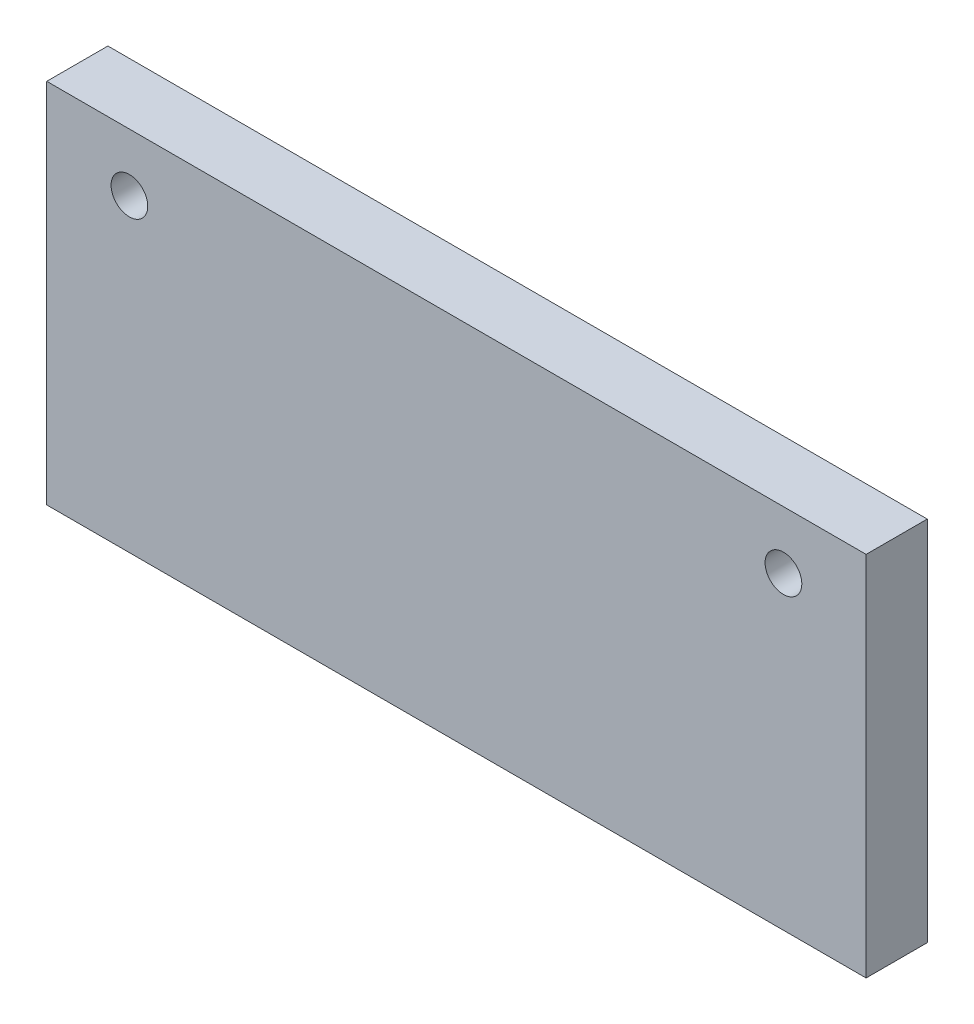
from build123d import *

# Parameters (mm, degrees)
CROQUIS1_W              = 134
CROQUIS1_H              = 60
CROQUIS1_R              = 3
SALIENTE_EXTRUIR1_DEPTH = 10


with BuildPart() as part:
    # Croquis1 → Saliente-Extruir1 (new body)
    with BuildSketch(Plane.XY):
        with Locations((67, 30)):
            Rectangle(CROQUIS1_W, CROQUIS1_H)
        with Locations((13.518676596, 50.556610738)):
            Circle(CROQUIS1_R, mode=Mode.SUBTRACT)
        with Locations((120.481323404, 50.556610738)):
            Circle(CROQUIS1_R, mode=Mode.SUBTRACT)
    extrude(amount=SALIENTE_EXTRUIR1_DEPTH)


solid = part.part
